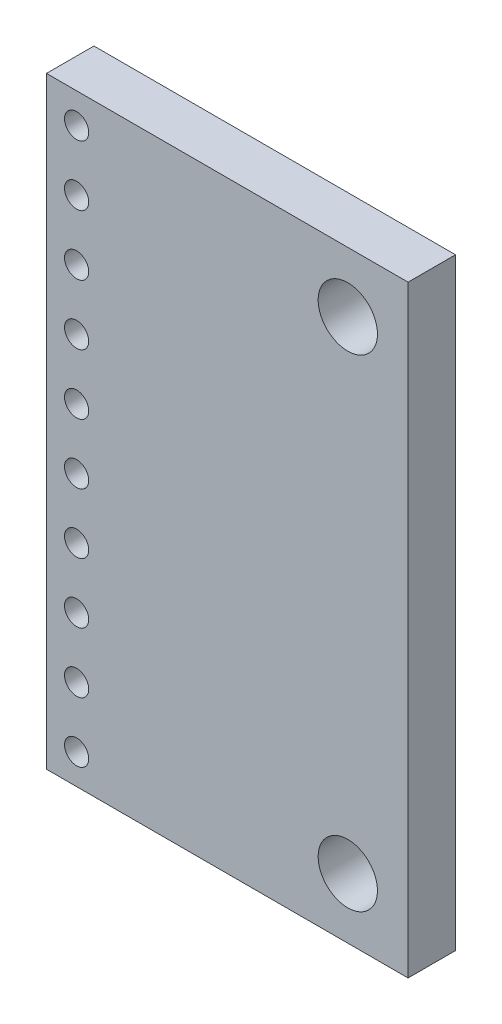
from build123d import *

# Parameters (mm, degrees)
SKETCH1_W           = 15.24
SKETCH1_H           = 25.4
SKETCH1_R           = 0.51
SKETCH1_R_2         = 1.25
BOSS_EXTRUDE1_DEPTH = 2


with BuildPart() as part:
    # Sketch1 → Boss-Extrude1 (new body)
    with BuildSketch(Plane.XY):
        with Locations((7.62, 12.7)):
            Rectangle(SKETCH1_W, SKETCH1_H)
        with Locations((1.27, 24.13)):
            Circle(SKETCH1_R, mode=Mode.SUBTRACT)
        with Locations((1.27, 21.59)):
            Circle(SKETCH1_R, mode=Mode.SUBTRACT)
        with Locations((1.27, 19.05)):
            Circle(SKETCH1_R, mode=Mode.SUBTRACT)
        with Locations((1.27, 16.51)):
            Circle(SKETCH1_R, mode=Mode.SUBTRACT)
        with Locations((1.27, 13.97)):
            Circle(SKETCH1_R, mode=Mode.SUBTRACT)
        with Locations((1.27, 11.43)):
            Circle(SKETCH1_R, mode=Mode.SUBTRACT)
        with Locations((1.27, 8.89)):
            Circle(SKETCH1_R, mode=Mode.SUBTRACT)
        with Locations((1.27, 6.35)):
            Circle(SKETCH1_R, mode=Mode.SUBTRACT)
        with Locations((1.27, 3.81)):
            Circle(SKETCH1_R, mode=Mode.SUBTRACT)
        with Locations((1.27, 1.27)):
            Circle(SKETCH1_R, mode=Mode.SUBTRACT)
        with Locations((12.7, 22.86)):
            Circle(SKETCH1_R_2, mode=Mode.SUBTRACT)
        with Locations((12.7, 2.54)):
            Circle(SKETCH1_R_2, mode=Mode.SUBTRACT)
    extrude(amount=BOSS_EXTRUDE1_DEPTH)


solid = part.part
